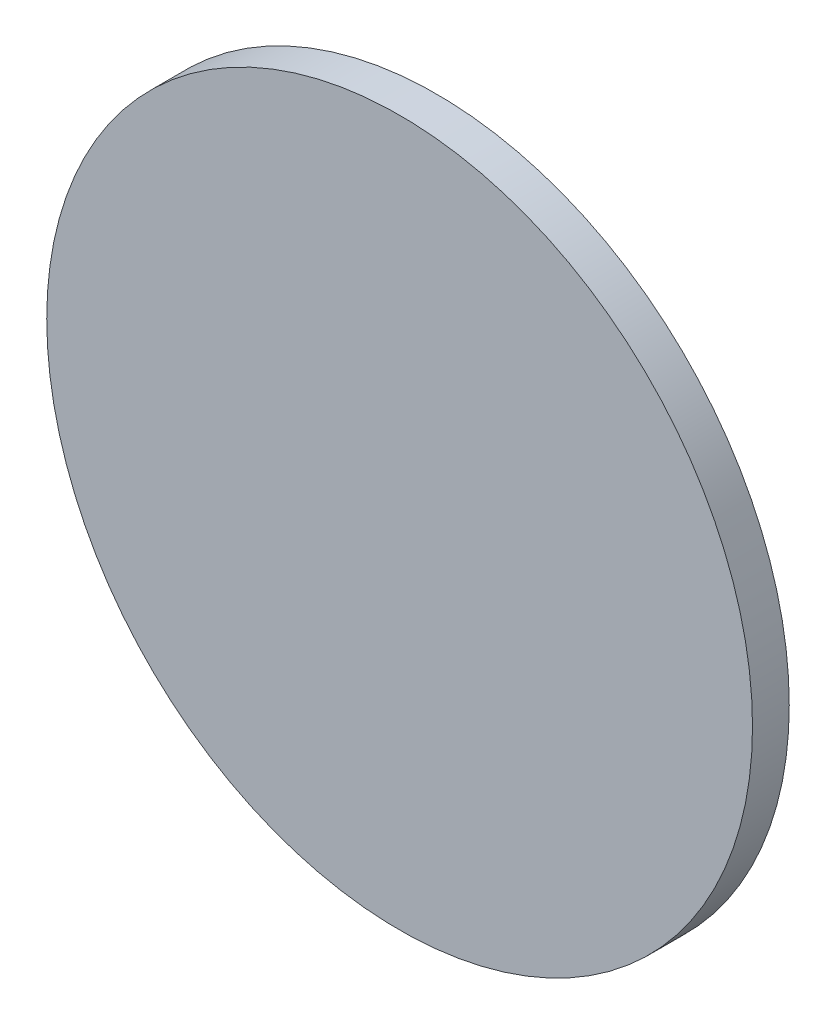
from build123d import *

# Parameters (mm, degrees)
ESQUISSE1_R        = 96
BOSS_EXTRU_1_DEPTH = 10


with BuildPart() as part:
    # Esquisse1 → Boss.-Extru.1 (new body)
    with BuildSketch(Plane.XY):
        Circle(ESQUISSE1_R)
    extrude(amount=BOSS_EXTRU_1_DEPTH)


solid = part.part
